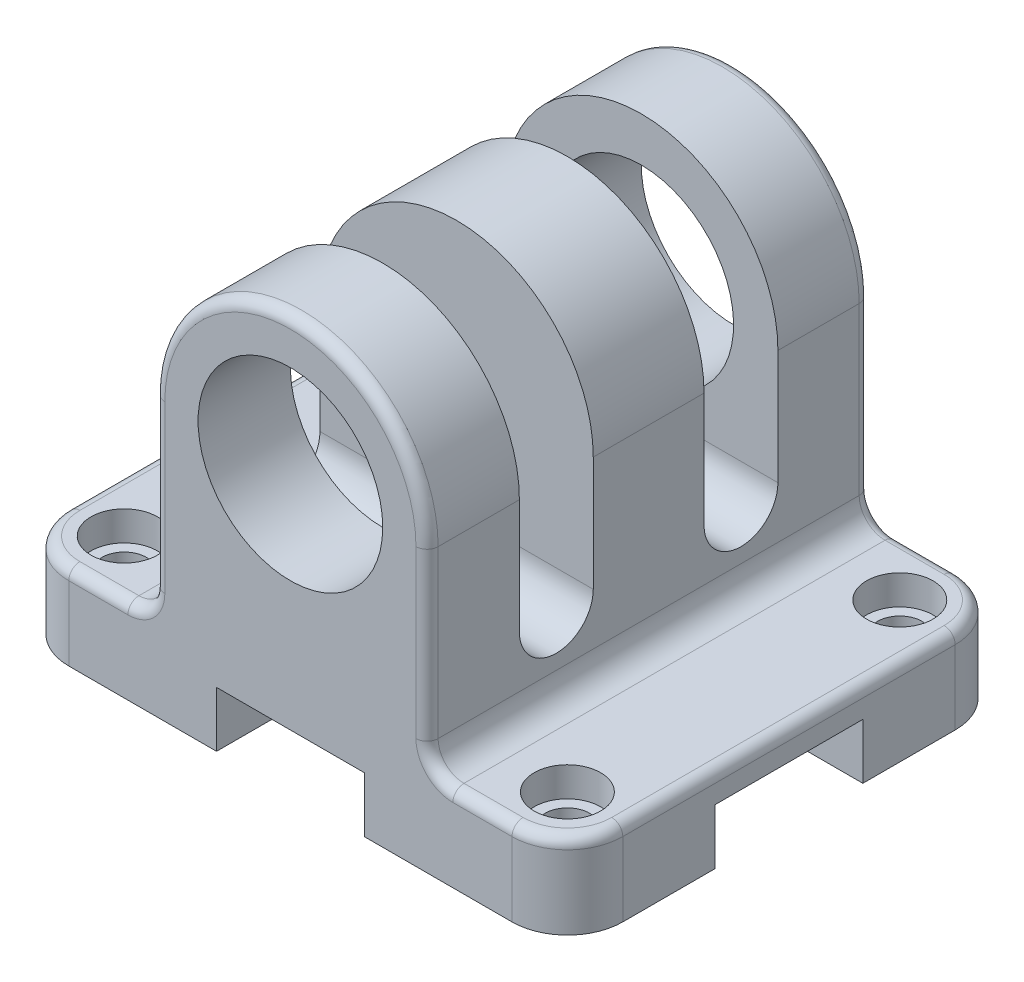
from build123d import *

# Parameters (mm, degrees)
EXTRUDE_1_DEPTH              = 60
SKETCH_3_W                   = 40
SKETCH_3_H                   = 15
CUT_EXTRUDE_1_DEPTH          = 76
CUT_EXTRUDE_1_DEPTH_BACK     = 76
SKETCH_4_R                   = 25
CUT_EXTRUDE_2_DEPTH          = 25
CUT_EXTRUDE_3_REACH          = 77
SKETCH_5_R                   = 7
FILLET_1_R                   = 15
HOLE_WIZARD_M2_1_D           = 12
HOLE_WIZARD_M2_1_CBORE_D     = 18
HOLE_WIZARD_M2_1_CBORE_DEPTH = 8
FILLET_2_R                   = 3
SKETCH_11_R                  = 45
CUT_EXTRUDE_4_DEPTH          = 15
SKETCH_12_R                  = 25
EXTRUDE_2_DEPTH              = 15


with BuildPart() as part:
    # 스케치1 → 보스-돌출1 (new body, symmetric)
    with BuildSketch(Plane.XY):
        with BuildLine():
            Line((-75, 0), (-20, 0))
            Line((-20, 0), (-20, 15))
            Line((-20, 15), (20, 15))
            Line((20, 15), (20, 0))
            Line((20, 0), (75, 0))
            Line((75, 0), (75, 23))
            Line((75, 23), (44, 23))
            ThreePointArc((44, 23), (39.050252532, 25.050252532), (37, 30))
            Line((37, 30), (37, 75))
            ThreePointArc((37, 75), (0, 112), (-37, 75))
            Line((-37, 75), (-37, 30))
            ThreePointArc((-37, 30), (-39.050252532, 25.050252532), (-44, 23))
            Line((-44, 23), (-75, 23))
            Line((-75, 23), (-75, 0))
        make_face()
    extrude(amount=EXTRUDE_1_DEPTH, both=True)

    # 스케치3 → 컷-돌출1 (cut, two sides)
    with BuildSketch(Plane(origin=(0, 0, 0), x_dir=(0, 0, -1), z_dir=(1, 0, 0))) as cut_extrude_1_sk:
        with BuildLine():
            Line((-35, 44), (-35, 156))
            ThreePointArc((-35, 156), (-25, 166), (-15, 156))
            Line((-15, 156), (-15, 44))
            ThreePointArc((-15, 44), (-25, 34), (-35, 44))
        make_face()
        with BuildLine():
            Line((35, 44), (35, 156))
            ThreePointArc((35, 156), (25, 166), (15, 156))
            Line((15, 156), (15, 44))
            ThreePointArc((15, 44), (25, 34), (35, 44))
        make_face()
        with Locations((0, 7.5)):
            Rectangle(SKETCH_3_W, SKETCH_3_H)
    extrude(amount=CUT_EXTRUDE_1_DEPTH, mode=Mode.SUBTRACT)
    extrude(cut_extrude_1_sk.sketch, amount=-CUT_EXTRUDE_1_DEPTH_BACK, mode=Mode.SUBTRACT)

    # 스케치4 → 컷-돌출2 (cut)
    with BuildSketch(Plane.XY.offset(60)):
        with Locations((0, 75)):
            Circle(SKETCH_4_R)
    cut_extrude_2 = extrude(amount=-CUT_EXTRUDE_2_DEPTH, mode=Mode.SUBTRACT)

    # 대칭 복사1: 컷-돌출2 across plane
    add(cut_extrude_2.mirror(Plane.XY), mode=Mode.SUBTRACT)

    # 스케치5 → 컷-돌출3 (cut, up to next)
    with BuildSketch(Plane.XY.offset(15), mode=Mode.PRIVATE) as cut_extrude_3_sk1:
        with Locations((0, 75)):
            Circle(SKETCH_5_R)
    cut_extrude_3_tool1 = extrude(cut_extrude_3_sk1.sketch, amount=-CUT_EXTRUDE_3_REACH, mode=Mode.PRIVATE) & part.part
    add(cut_extrude_3_tool1.solids().sort_by_distance((0, 75, 15))[0], mode=Mode.SUBTRACT)

    # 필렛1
    fillet_1_edges = [part.edges().sort_by_distance(p)[0] for p in [
        (75, 11.5, -60),
        (-75, 11.5, -60),
        (75, 11.5, 60),
        (-75, 11.5, 60),
    ]]
    fillet(fillet_1_edges, radius=FILLET_1_R)

    # M2 소켓 머리 캡 나사용 카운터보어1 (through all)
    with Locations(Plane(origin=(0, 23, 0), x_dir=(1, 0, 0), z_dir=(0, 1, 0))):
        with Locations((-60, 45), (-60, -45)):
            hole_wizard_m2_1 = CounterBoreHole(HOLE_WIZARD_M2_1_D / 2, HOLE_WIZARD_M2_1_CBORE_D / 2, HOLE_WIZARD_M2_1_CBORE_DEPTH)

    # 대칭 복사2: M2 소켓 머리 캡 나사용 카운터보어1 across plane
    add(hole_wizard_m2_1.mirror(Plane(origin=(0, 0, 0), x_dir=(0, 0, 1), z_dir=(1, 0, 0))), mode=Mode.SUBTRACT)

    # 필렛2
    fillet_2_edges = [part.edges().sort_by_distance(p)[0] for p in [
        (-75, 23, 0),
        (-52, 23, -60),
        (52, 23, -60),
        (-70.606601718, 23, 55.606601718),
        (-70.606601718, 23, -55.606601718),
        (-39.050252532, 25.050252532, -60),
        (75, 23, 0),
        (52, 23, 60),
        (70.606601718, 23, 55.606601718),
        (70.606601718, 23, -55.606601718),
        (-37, 52.5, -60),
        (0, 112, -60),
        (37, 52.5, -60),
        (39.050252532, 25.050252532, -60),
        (39.050252532, 25.050252532, 60),
        (37, 52.5, 60),
        (0, 112, 60),
        (-37, 52.5, 60),
        (-39.050252532, 25.050252532, 60),
        (-52, 23, 60),
    ]]
    fillet(fillet_2_edges, radius=FILLET_2_R)

    # 스케치11 → 컷-돌출4 (cut)
    with BuildSketch(Plane.XZ):
        Circle(SKETCH_11_R)
    extrude(amount=-CUT_EXTRUDE_4_DEPTH, mode=Mode.SUBTRACT)

    # 스케치12 → 보스-돌출2 (add)
    with BuildSketch(Plane.XZ.offset(-15)):
        Circle(SKETCH_12_R)
    extrude(amount=EXTRUDE_2_DEPTH)


solid = part.part
